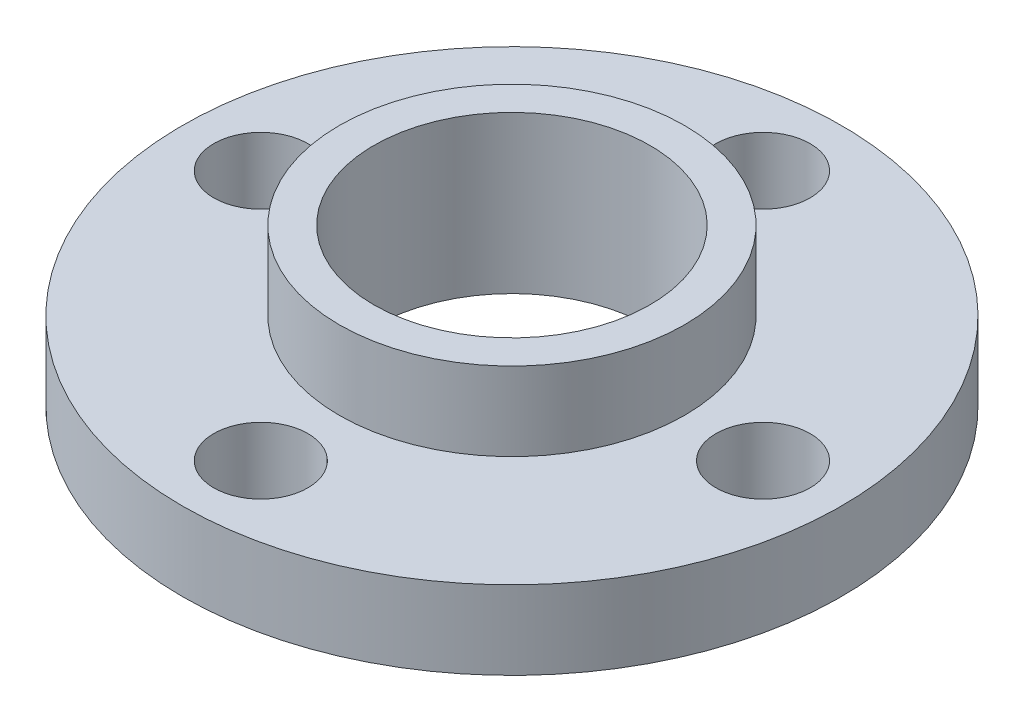
from build123d import *

# Parameters (mm, degrees)
SKETCH_1_R               = 10.5
SKETCH_1_R_2             = 4.4
EXTRUDE_1_DEPTH          = 2.5
SKETCH_2_R               = 5.5
SKETCH_2_R_2             = 4.4
EXTRUDE_2_DEPTH          = 2.5
SKETCH_3_R               = 1.5
CUT_EXTRUDE_1_DEPTH      = 3.5
PATTERN_CIRCULAR_2_COUNT = 4


with BuildPart() as part:
    # Эскиз1 → Бобышка-Вытянуть1 (new body)
    with BuildSketch(Plane(origin=(0, 0, 0), x_dir=(1, 0, 0), z_dir=(0, 1, 0))):
        Circle(SKETCH_1_R)
        Circle(SKETCH_1_R_2, mode=Mode.SUBTRACT)
    extrude(amount=EXTRUDE_1_DEPTH)

    # Эскиз2 → Бобышка-Вытянуть2 (add)
    with BuildSketch(Plane(origin=(0, 2.5, 0), x_dir=(1, 0, 0), z_dir=(0, 1, 0))):
        Circle(SKETCH_2_R)
        Circle(SKETCH_2_R_2, mode=Mode.SUBTRACT)
    extrude(amount=EXTRUDE_2_DEPTH)

    # Эскиз3 → Вырез-Вытянуть1 (cut, through all)
    with BuildSketch(Plane(origin=(0, 2.5, 0), x_dir=(1, 0, 0), z_dir=(0, 1, 0))):
        with Locations((-8, 0)):
            Circle(SKETCH_3_R)
    cut_extrude_1 = extrude(amount=-CUT_EXTRUDE_1_DEPTH, mode=Mode.SUBTRACT)

    # Круговой массив2: Вырез-Вытянуть1 ×4 about axis
    pattern_circular_2_axis = Axis((0, 0, 0), (0, 1, 0))
    for i in range(1, PATTERN_CIRCULAR_2_COUNT):
        add(cut_extrude_1.rotate(pattern_circular_2_axis, i * 360 / PATTERN_CIRCULAR_2_COUNT), mode=Mode.SUBTRACT)


solid = part.part
